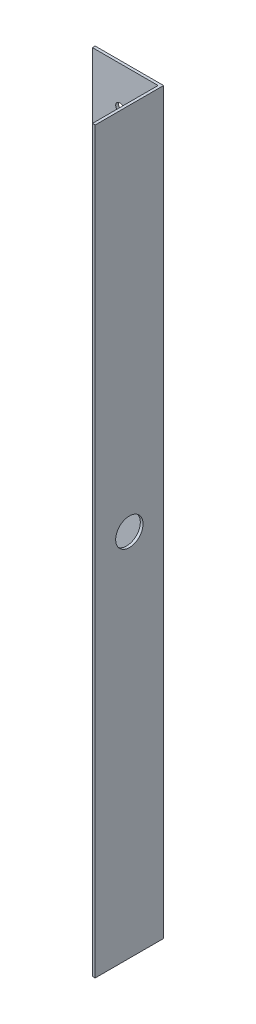
from build123d import *

# Parameters (mm, degrees)
CROQUIS1_W              = 24
CROQUIS1_H              = 270
CROQUIS1_R              = 1.5
SALIENTE_EXTRUIR1_DEPTH = 1
CROQUIS2_W              = 1
CROQUIS2_H              = 270
SALIENTE_EXTRUIR2_DEPTH = 25
CROQUIS3_R              = 5
CORTAR_EXTRUIR1_DEPTH   = 1


with BuildPart() as part:
    # Croquis1 → Saliente-Extruir1 (new body)
    with BuildSketch(Plane.XY):
        with Locations((-41.401725042, -108.514805415)):
            Rectangle(CROQUIS1_W, CROQUIS1_H)
        with Locations((-43.401725042, 12.485194585)):
            Circle(CROQUIS1_R, mode=Mode.SUBTRACT)
        with Locations((-43.401725042, -229.514805415)):
            Circle(CROQUIS1_R, mode=Mode.SUBTRACT)
    extrude(amount=SALIENTE_EXTRUIR1_DEPTH)

    # Croquis2 → Saliente-Extruir2 (add)
    with BuildSketch(Plane.XY):
        with Locations((-28.901725042, -108.514805415)):
            Rectangle(CROQUIS2_W, CROQUIS2_H)
    extrude(amount=SALIENTE_EXTRUIR2_DEPTH)

    # Croquis3 → Cortar-Extruir1 (cut)
    with BuildSketch(Plane(origin=(-28.401725042, 0, 0), x_dir=(0, 0, -1), z_dir=(1, 0, 0))):
        with Locations((-12.5, -108.514805415)):
            Circle(CROQUIS3_R)
    extrude(amount=-CORTAR_EXTRUIR1_DEPTH, mode=Mode.SUBTRACT)


solid = part.part
